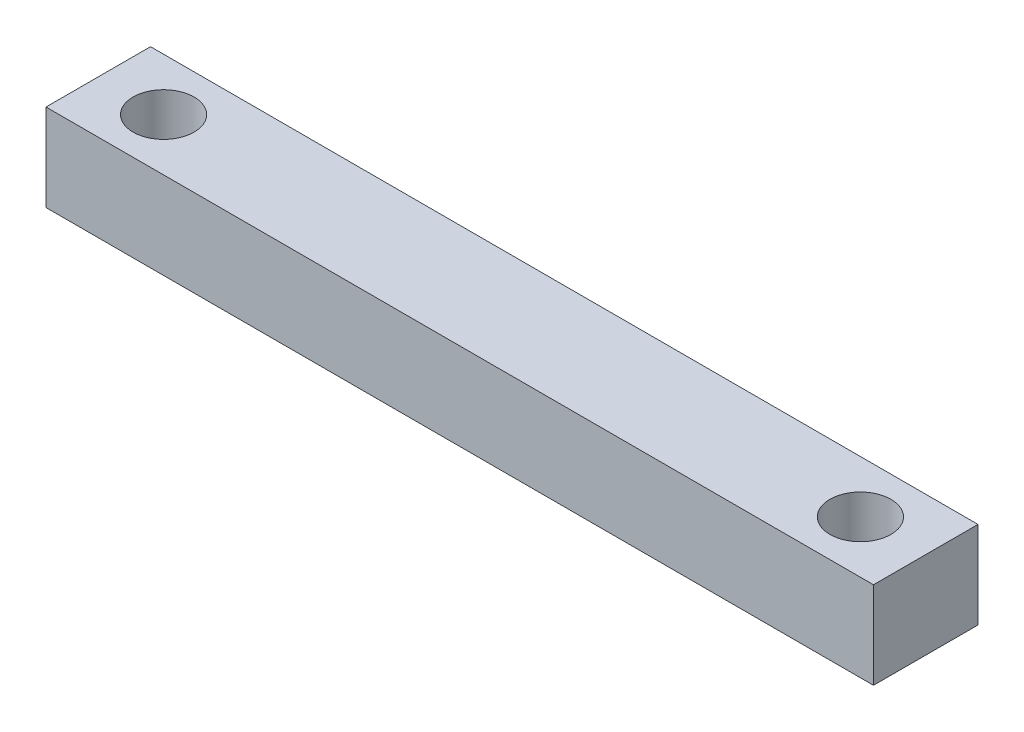
from build123d import *

# Parameters (mm, degrees)
SKETCH1_W           = 47.5
SKETCH1_H           = 6
SKETCH1_R           = 1.75
BOSS_EXTRUDE1_DEPTH = 5


with BuildPart() as part:
    # Sketch1 → Boss-Extrude1 (new body)
    with BuildSketch(Plane(origin=(0, 0, 0), x_dir=(1, 0, 0), z_dir=(0, 1, 0))):
        Rectangle(SKETCH1_W, SKETCH1_H)
        with Locations((-20, 0)):
            Circle(SKETCH1_R, mode=Mode.SUBTRACT)
        with Locations((20, 0)):
            Circle(SKETCH1_R, mode=Mode.SUBTRACT)
    extrude(amount=BOSS_EXTRUDE1_DEPTH)


solid = part.part
